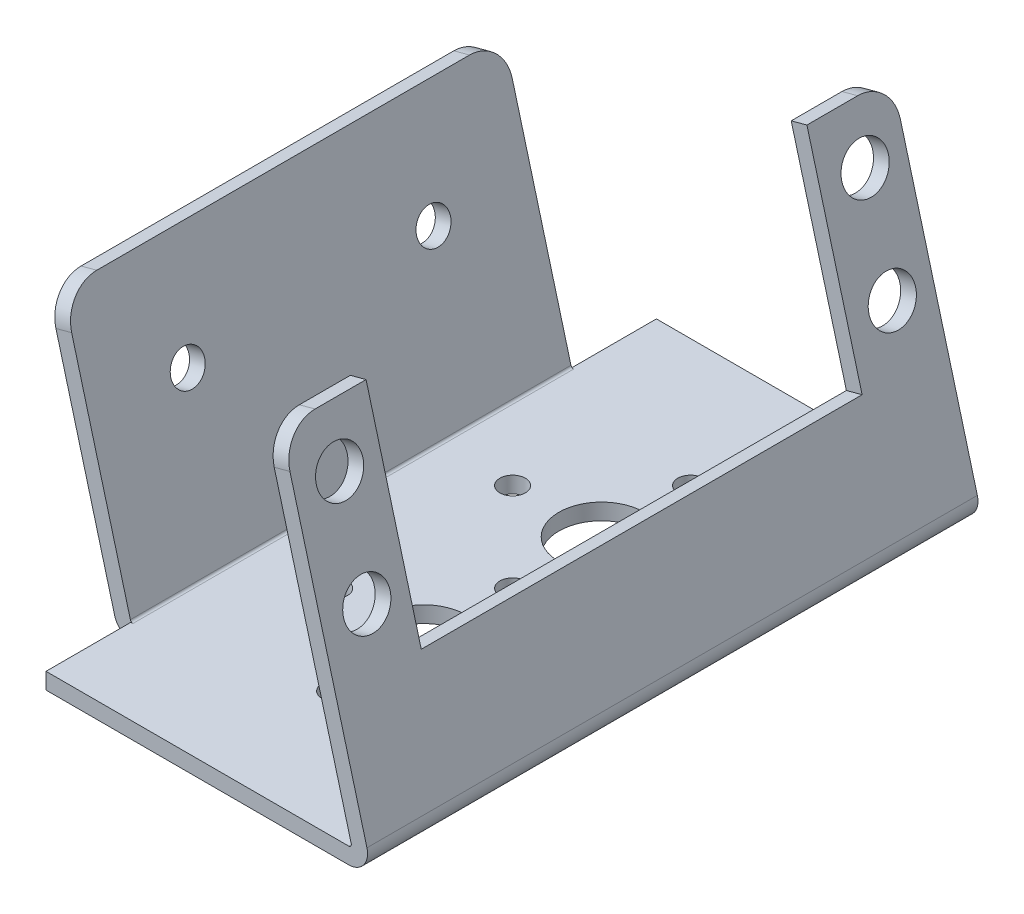
from build123d import *

# Parameters (mm, degrees)
EXTRUDE1_DEPTH      = 28.575
CUT_EXTRUDE1_REACH  = 34.214
SKETCH2_R           = 4.0005
SKETCH2_R_2         = 1.1938
SKETCH21_R          = 4.0005
SKETCH21_R_2        = 1.1938
CUT_EXTRUDE11_DEPTH = 1.524
CUT_EXTRUDE13_REACH = 39.179
SKETCH23_W          = 41.275
SKETCH23_H          = 19.9644
CUT_EXTRUDE14_REACH = 39.179
SKETCH24_R          = 2.1844
CUT_EXTRUDE16_REACH = 41.072
SKETCH26_R          = 1.5875
SKETCH27_W          = 12.7
SKETCH27_H          = 7.9502
CUT_EXTRUDE17_DEPTH = 33.213819492
FILLET1_R           = 0.254
FILLET2_R           = 1.778
FILLET3_R           = 3.175


with BuildPart() as part:
    # Sketch1 → Extrude1 (new body, symmetric)
    with BuildSketch(Plane.XY):
        Polygon((-22.954013802, 24.902533728), (-16.2814, 0), (15.536778129, 0), (6.905111211, 32.213819492), (5.433040251, 31.819379267), (13.550662661, 1.524), (-15.11199367, 1.524), (-21.481942843, 25.296973952), align=None)
    extrude(amount=EXTRUDE1_DEPTH, both=True)

    # Sketch2 → Cut-Extrude1 (cut, up to next)
    with BuildSketch(Plane(origin=(0.432553042, 0, 10.730384283), x_dir=(-1, 0, 0), z_dir=(0, 1, 0)), mode=Mode.PRIVATE) as cut_extrude1_sk1:
        with Locations(Location((0.432553042, -2.399184283, 0), (0, 0, 270))):  # turned: the seam where the file's is
            Circle(SKETCH2_R)
    cut_extrude1_tool1 = extrude(cut_extrude1_sk1.sketch, amount=CUT_EXTRUDE1_REACH, mode=Mode.PRIVATE) & part.part
    add(cut_extrude1_tool1.solids().sort_by_distance((0, 0, 8.3312))[0], mode=Mode.SUBTRACT)
    # Sketch2 → Cut-Extrude1 (cut, up to next)
    with BuildSketch(Plane(origin=(0.432553042, 0, 10.730384283), x_dir=(-1, 0, 0), z_dir=(0, 1, 0)), mode=Mode.PRIVATE) as cut_extrude1_sk2:
        with Locations(Location((0.432553042, 5.932015717, 0), (0, 0, 270))):  # turned: the seam where the file's is
            Circle(SKETCH2_R_2)
    cut_extrude1_tool2 = extrude(cut_extrude1_sk2.sketch, amount=CUT_EXTRUDE1_REACH, mode=Mode.PRIVATE) & part.part
    add(cut_extrude1_tool2.solids().sort_by_distance((0, 0, 16.6624))[0], mode=Mode.SUBTRACT)
    # Sketch2 → Cut-Extrude1 (cut, up to next)
    with BuildSketch(Plane(origin=(0.432553042, 0, 10.730384283), x_dir=(-1, 0, 0), z_dir=(0, 1, 0)), mode=Mode.PRIVATE) as cut_extrude1_sk3:
        with Locations(Location((8.763753042, -2.399184283, 0), (0, 0, 270))):  # turned: the seam where the file's is
            Circle(SKETCH2_R_2)
    cut_extrude1_tool3 = extrude(cut_extrude1_sk3.sketch, amount=CUT_EXTRUDE1_REACH, mode=Mode.PRIVATE) & part.part
    add(cut_extrude1_tool3.solids().sort_by_distance((-8.3312, 0, 8.3312))[0], mode=Mode.SUBTRACT)
    # Sketch2 → Cut-Extrude1 (cut, up to next)
    with BuildSketch(Plane(origin=(0.432553042, 0, 10.730384283), x_dir=(-1, 0, 0), z_dir=(0, 1, 0)), mode=Mode.PRIVATE) as cut_extrude1_sk4:
        with Locations(Location((0.432553042, -10.730384283, 0), (0, 0, 270))):  # turned: the seam where the file's is
            Circle(SKETCH2_R_2)
    cut_extrude1_tool4 = extrude(cut_extrude1_sk4.sketch, amount=CUT_EXTRUDE1_REACH, mode=Mode.PRIVATE) & part.part
    add(cut_extrude1_tool4.solids().sort_by_distance((0, 0, 0))[0], mode=Mode.SUBTRACT)
    # Sketch2 → Cut-Extrude1 (cut, up to next)
    with BuildSketch(Plane(origin=(0.432553042, 0, 10.730384283), x_dir=(-1, 0, 0), z_dir=(0, 1, 0)), mode=Mode.PRIVATE) as cut_extrude1_sk5:
        with Locations(Location((-7.898646958, -2.399184283, 0), (0, 0, 270))):  # turned: the seam where the file's is
            Circle(SKETCH2_R_2)
    cut_extrude1_tool5 = extrude(cut_extrude1_sk5.sketch, amount=CUT_EXTRUDE1_REACH, mode=Mode.PRIVATE) & part.part
    add(cut_extrude1_tool5.solids().sort_by_distance((8.3312, 0, 8.3312))[0], mode=Mode.SUBTRACT)

    # Sketch21 → Cut-Extrude11 (cut)
    with BuildSketch(Plane(origin=(1.025651892, 0, -16.036287214), x_dir=(-1, 0, 0), z_dir=(0, 1, 0))):
        with Locations(Location((1.025651892, 7.705087214, 0), (0, 0, 270))):  # turned: the seam where the file's is
            Circle(SKETCH21_R)
        with Locations(Location((1.025651892, 16.036287214, 0), (0, 0, 270))):  # turned: the seam where the file's is
            Circle(SKETCH21_R_2)
        with Locations(Location((9.356851892, 7.705087214, 0), (0, 0, 270))):  # turned: the seam where the file's is
            Circle(SKETCH21_R_2)
        with Locations(Location((1.025651892, -0.626112786, 0), (0, 0, 270))):  # turned: the seam where the file's is
            Circle(SKETCH21_R_2)
        with Locations(Location((-7.305548108, 7.705087214, 0), (0, 0, 270))):  # turned: the seam where the file's is
            Circle(SKETCH21_R_2)
    extrude(amount=CUT_EXTRUDE11_DEPTH, mode=Mode.SUBTRACT)

    # Sketch23 → Cut-Extrude13 (cut, up to next)
    with BuildSketch(Plane(origin=(14.496011341, 3.884194532, 0), x_dir=(0, 0, -1), z_dir=(0.965925826, 0.258819045, 0)), mode=Mode.PRIVATE) as cut_extrude13_sk1:
        with Locations((0.0127, 19.346785921)):
            Rectangle(SKETCH23_W, SKETCH23_H)
    cut_extrude13_tool1 = extrude(cut_extrude13_sk1.sketch, amount=-CUT_EXTRUDE13_REACH, mode=Mode.PRIVATE) & part.part
    add(cut_extrude13_tool1.solids().sort_by_distance((9.488695, 22.571755, -0.0127))[0], mode=Mode.SUBTRACT)

    # Sketch24 → Cut-Extrude14 (cut, up to next)
    with BuildSketch(Plane(origin=(14.496011341, 3.884194532, 0), x_dir=(0, 0, -1), z_dir=(0.965925826, 0.258819045, 0)), mode=Mode.PRIVATE) as cut_extrude14_sk1:
        with Locations(Location((-24.4094, 24.274385921, 0), (0, 0, 90))):  # turned: the seam where the file's is
            Circle(SKETCH24_R)
    cut_extrude14_tool1 = extrude(cut_extrude14_sk1.sketch, amount=-CUT_EXTRUDE14_REACH, mode=Mode.PRIVATE) & part.part
    add(cut_extrude14_tool1.solids().sort_by_distance((8.213338, 27.331451, 24.4094))[0], mode=Mode.SUBTRACT)
    # Sketch24 → Cut-Extrude14 (cut, up to next)
    with BuildSketch(Plane(origin=(14.496011341, 3.884194532, 0), x_dir=(0, 0, -1), z_dir=(0.965925826, 0.258819045, 0)), mode=Mode.PRIVATE) as cut_extrude14_sk2:
        with Locations(Location((-24.4094, 14.444585921, 0), (0, 0, 90))):  # turned: the seam where the file's is
            Circle(SKETCH24_R)
    cut_extrude14_tool2 = extrude(cut_extrude14_sk2.sketch, amount=-CUT_EXTRUDE14_REACH, mode=Mode.PRIVATE) & part.part
    add(cut_extrude14_tool2.solids().sort_by_distance((10.757477, 17.836593, 24.4094))[0], mode=Mode.SUBTRACT)
    # Sketch24 → Cut-Extrude14 (cut, up to next)
    with BuildSketch(Plane(origin=(14.496011341, 3.884194532, 0), x_dir=(0, 0, -1), z_dir=(0.965925826, 0.258819045, 0)), mode=Mode.PRIVATE) as cut_extrude14_sk3:
        with Locations(Location((24.7904, 24.274385921, 0), (0, 0, 90))):  # turned: the seam where the file's is
            Circle(SKETCH24_R)
    cut_extrude14_tool3 = extrude(cut_extrude14_sk3.sketch, amount=-CUT_EXTRUDE14_REACH, mode=Mode.PRIVATE) & part.part
    add(cut_extrude14_tool3.solids().sort_by_distance((8.213338, 27.331451, -24.7904))[0], mode=Mode.SUBTRACT)
    # Sketch24 → Cut-Extrude14 (cut, up to next)
    with BuildSketch(Plane(origin=(14.496011341, 3.884194532, 0), x_dir=(0, 0, -1), z_dir=(0.965925826, 0.258819045, 0)), mode=Mode.PRIVATE) as cut_extrude14_sk4:
        with Locations(Location((24.7904, 14.444585921, 0), (0, 0, 90))):  # turned: the seam where the file's is
            Circle(SKETCH24_R)
    cut_extrude14_tool4 = extrude(cut_extrude14_sk4.sketch, amount=-CUT_EXTRUDE14_REACH, mode=Mode.PRIVATE) & part.part
    add(cut_extrude14_tool4.solids().sort_by_distance((10.757477, 17.836593, -24.7904))[0], mode=Mode.SUBTRACT)

    # Sketch26 → Cut-Extrude16 (cut, up to next)
    with BuildSketch(Plane(origin=(-15.190753005, -4.07035, 0), x_dir=(0, 0, 1), z_dir=(-0.965925826, -0.258819045, 0)), mode=Mode.PRIVATE) as cut_extrude16_sk1:
        with Locations(Location((-11.5062, 20.063536401, 0), (0, 0, 270))):  # turned: the seam where the file's is
            Circle(SKETCH26_R)
    cut_extrude16_tool1 = extrude(cut_extrude16_sk1.sketch, amount=-CUT_EXTRUDE16_REACH, mode=Mode.PRIVATE) & part.part
    add(cut_extrude16_tool1.solids().sort_by_distance((-20.383578, 15.309538, -11.5062))[0], mode=Mode.SUBTRACT)
    # Sketch26 → Cut-Extrude16 (cut, up to next)
    with BuildSketch(Plane(origin=(-15.190753005, -4.07035, 0), x_dir=(0, 0, 1), z_dir=(-0.965925826, -0.258819045, 0)), mode=Mode.PRIVATE) as cut_extrude16_sk2:
        with Locations(Location((11.5062, 20.063536401, 0), (0, 0, 270))):  # turned: the seam where the file's is
            Circle(SKETCH26_R)
    cut_extrude16_tool2 = extrude(cut_extrude16_sk2.sketch, amount=-CUT_EXTRUDE16_REACH, mode=Mode.PRIVATE) & part.part
    add(cut_extrude16_tool2.solids().sort_by_distance((-20.383578, 15.309538, 11.5062))[0], mode=Mode.SUBTRACT)

    # Sketch27 → Cut-Extrude17 (cut, through all)
    with BuildSketch(Plane.XZ):
        with Locations((-21.46199367, 24.5999)):
            Rectangle(SKETCH27_W, SKETCH27_H)
        with Locations((-21.46199367, -24.5999)):
            Rectangle(SKETCH27_W, SKETCH27_H)
    extrude(amount=-CUT_EXTRUDE17_DEPTH, mode=Mode.SUBTRACT)

    # Fillet1
    fillet1_edges = [part.edges().sort_by_distance(p)[0] for p in [
        (-15.11199367, 1.524, 0),
        (13.550662661, 1.524, 0),
    ]]
    fillet(fillet1_edges, radius=FILLET1_R)

    # Fillet2
    fillet2_edges = [part.edges().sort_by_distance(p)[0] for p in [
        (15.536778129, 0, 0),
        (-16.2814, 0, 0),
    ]]
    fillet(fillet2_edges, radius=FILLET2_R)

    # Fillet3
    fillet3_edges = [part.edges().sort_by_distance(p)[0] for p in [
        (-22.217978322, 25.09975384, 20.6248),
        (-22.217978322, 25.09975384, -20.6248),
        (6.169075731, 32.01659938, 28.575),
        (6.169075731, 32.01659938, -28.575),
    ]]
    fillet(fillet3_edges, radius=FILLET3_R)


solid = part.part
